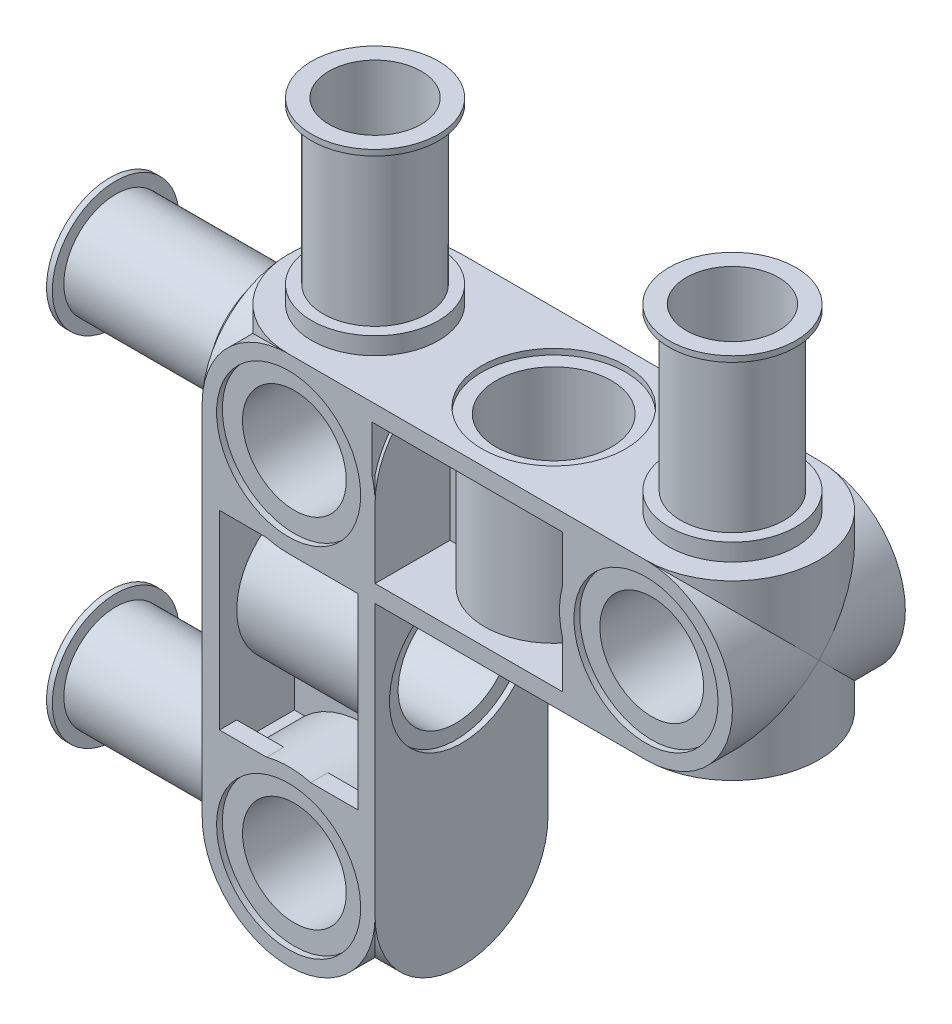
from build123d import *

# Parameters (mm, degrees)
EXTRUDE1_DEPTH       = 3.81
SKETCH2_R            = 2.794
CUT_EXTRUDE1_DEPTH   = 0.254
SKETCH3_R            = 2.794
EXTRUDE2_DEPTH       = 0.762
SKETCH5_R            = 2.286
SKETCH5_R_2          = 2.032
EXTRUDE4_DEPTH       = 7.112
SKETCH6_R            = 2.794
SKETCH6_R_2          = 2.032
EXTRUDE5_DEPTH       = 0.254
EXTRUDE6_DEPTH       = 7.62
SKETCH8_R            = 2.54
CUT_EXTRUDE2_DEPTH   = 3.556
SKETCH9_R            = 2.286
CUT_EXTRUDE3_DEPTH   = 8.62
SKETCH10_R           = 3.175
CUT_EXTRUDE4_DEPTH   = 0.254
CUT_EXTRUDE6_DEPTH   = 3.048
SKETCH13_R           = 2.54
CUT_EXTRUDE7_DEPTH   = 9.128
SKETCH14_R           = 3.175
CUT_EXTRUDE8_DEPTH   = 0.254
EXTRUDE8_DEPTH       = 7.112
EXTRUDE10_DEPTH      = 1
EXTRUDE10_DEPTH_BACK = 8.62
CIRPATTERN1_COUNT    = 2
CIRPATTERN1_ANGLE    = 90


with BuildPart() as part:
    # Sketch1 → Extrude1 (new body)
    with BuildSketch(Plane(origin=(0, 0, 0), x_dir=(1, 0, 0), z_dir=(0, 1, 0))):
        with BuildLine():
            Line((-7.874, 3.81), (7.874, 3.81))
            ThreePointArc((7.874, 3.81), (11.684, 0), (7.874, -3.81))
            Line((7.874, -3.81), (-7.874, -3.81))
            ThreePointArc((-7.874, -3.81), (-11.684, 0), (-7.874, 3.81))
        make_face()
    extrude(amount=EXTRUDE1_DEPTH)

    # Sketch2 → Cut-Extrude1 (cut)
    with BuildSketch(Plane.XZ):
        Circle(SKETCH2_R)
    extrude(amount=-CUT_EXTRUDE1_DEPTH, mode=Mode.SUBTRACT)

    # Sketch3 → Extrude2 (add)
    with BuildSketch(Plane.XZ):
        with Locations((7.874, 0)):
            Circle(SKETCH3_R)
        with Locations((-7.874, 0)):
            Circle(SKETCH3_R)
    extrude(amount=EXTRUDE2_DEPTH)

    # Sketch5 → Extrude4 (add)
    with BuildSketch(Plane.XZ.offset(0.762)):
        with Locations((7.874, 0)):
            Circle(SKETCH5_R)
        with Locations((7.874, 0)):
            Circle(SKETCH5_R_2, mode=Mode.SUBTRACT)
        with Locations((-7.874, 0)):
            Circle(SKETCH5_R)
        with Locations((-7.874, 0)):
            Circle(SKETCH5_R_2, mode=Mode.SUBTRACT)
    extrude(amount=EXTRUDE4_DEPTH)

    # Sketch6 → Extrude5 (add)
    with BuildSketch(Plane.XZ.offset(7.874)):
        with Locations((-7.874, 0)):
            Circle(SKETCH6_R)
        with Locations((-7.874, 0)):
            Circle(SKETCH6_R_2, mode=Mode.SUBTRACT)
        with Locations((7.874, 0)):
            Circle(SKETCH6_R)
        with Locations((7.874, 0)):
            Circle(SKETCH6_R_2, mode=Mode.SUBTRACT)
    extrude(amount=-EXTRUDE5_DEPTH)

    # Sketch7 → Extrude6 (add)
    with BuildSketch(Plane(origin=(0, 0, -3.81), x_dir=(-1, 0, 0), z_dir=(0, 0, -1))):
        with BuildLine():
            Line((-7.874, 0), (7.874, 0))
            ThreePointArc((7.874, 0), (10.568076836, 1.115923164), (11.684, 3.81))
            Line((11.684, 3.81), (7.874, 3.81))
            Line((7.874, 3.81), (-7.874, 3.81))
            Line((-7.874, 3.81), (-11.684, 3.81))
            ThreePointArc((-11.684, 3.81), (-10.568076836, 1.115923164), (-7.874, 0))
        make_face()
    extrude(amount=-EXTRUDE6_DEPTH)

    # Sketch8 → Cut-Extrude2 (cut)
    with BuildSketch(Plane(origin=(0, 3.81, 0), x_dir=(1, 0, 0), z_dir=(0, 1, 0))):
        Circle(SKETCH8_R)
    extrude(amount=-CUT_EXTRUDE2_DEPTH, mode=Mode.SUBTRACT)

    # Sketch9 → Cut-Extrude3 (cut, through all)
    with BuildSketch(Plane.XY.offset(3.81)):
        with Locations((7.874, 3.81)):
            Circle(SKETCH9_R)
        with Locations((-7.874, 3.81)):
            Circle(SKETCH9_R)
    extrude(amount=-CUT_EXTRUDE3_DEPTH, mode=Mode.SUBTRACT)

    # Sketch10 → Cut-Extrude4 (cut)
    with BuildSketch(Plane.XY.offset(3.81)):
        with Locations((7.874, 3.81)):
            Circle(SKETCH10_R)
        with Locations((-7.874, 3.81)):
            Circle(SKETCH10_R)
    cut_extrude4 = extrude(amount=-CUT_EXTRUDE4_DEPTH, mode=Mode.SUBTRACT)

    # Mirror2: Cut-Extrude4 across plane
    add(cut_extrude4.mirror(Plane.XY), mode=Mode.SUBTRACT)

    # Sketch11 → Cut-Extrude6 (cut)
    with BuildSketch(Plane(origin=(0, 3.81, 0), x_dir=(1, 0, 0), z_dir=(0, 1, 0))):
        with BuildLine():
            Line((-5.08, -0.508), (-5.08, -3.048))
            Line((-5.08, -3.048), (-4.191, -3.048))
            Line((-4.191, -3.048), (-4.191, -3.81))
            Line((-4.191, -3.81), (4.191, -3.81))
            Line((4.191, -3.81), (4.191, -3.048))
            Line((4.191, -3.048), (5.08, -3.048))
            Line((5.08, -3.048), (5.08, -0.508))
            Line((5.08, -0.508), (3.00536853, -0.508))
            ThreePointArc((3.00536853, -0.508), (0, -3.048), (-3.00536853, -0.508))
            Line((-3.00536853, -0.508), (-5.08, -0.508))
        make_face()
        with BuildLine():
            Line((5.08, 0.508), (5.08, 3.048))
            Line((5.08, 3.048), (4.191, 3.048))
            Line((4.191, 3.048), (4.191, 3.81))
            Line((4.191, 3.81), (-4.191, 3.81))
            Line((-4.191, 3.81), (-4.191, 3.048))
            Line((-4.191, 3.048), (-5.08, 3.048))
            Line((-5.08, 3.048), (-5.08, 0.508))
            Line((-5.08, 0.508), (-3.00536853, 0.508))
            ThreePointArc((-3.00536853, 0.508), (0, 3.048), (3.00536853, 0.508))
            Line((3.00536853, 0.508), (5.08, 0.508))
        make_face()
    extrude(amount=-CUT_EXTRUDE6_DEPTH, mode=Mode.SUBTRACT)

    # Sketch13 → Cut-Extrude7 (cut, through all)
    with BuildSketch(Plane(origin=(0, 0.254, 0), x_dir=(1, 0, 0), z_dir=(0, 1, 0))):
        Circle(SKETCH13_R)
    extrude(amount=-CUT_EXTRUDE7_DEPTH, mode=Mode.SUBTRACT)

    # Sketch14 → Cut-Extrude8 (cut)
    with BuildSketch(Plane.XZ):
        Circle(SKETCH14_R)
    extrude(amount=-CUT_EXTRUDE8_DEPTH, mode=Mode.SUBTRACT)

    # Sketch17 → Extrude8 (add)
    with BuildSketch(Plane.XY.offset(3.81)):
        with BuildLine():
            Line((-4.064, 3.81), (-4.699, 3.81))
            ThreePointArc((-4.699, 3.81), (-7.874, 0.635), (-11.049, 3.81))
            Line((-11.049, 3.81), (-11.684, 3.81))
            ThreePointArc((-11.684, 3.81), (-7.874, 0), (-4.064, 3.81))
        make_face()
    extrude8 = extrude(amount=-EXTRUDE8_DEPTH)

    # Mirror3: Extrude8 across plane
    add(extrude8.mirror(Plane(origin=(0, 0, 0), x_dir=(0, 0, 1), z_dir=(1, 0, 0))))

    # Mirror1: part across face


with BuildPart() as part_1:
    add(part.part)
    add(part.part.mirror(Plane(origin=(0, 3.81, 0.015641894), x_dir=(0, 0, 1), z_dir=(0, 1, 0))))

    # Sketch18 → Extrude10 (cut, two sides)
    with BuildSketch(Plane.XY.offset(3.81)) as extrude10_sk:
        Polygon((-86.944177943, 0), (-14.134519373, 0), (15.632648155, 0), (88.442306725, 0), (88.442306725, -145.61931714), (-86.944177943, -145.61931714), align=None)
    extrude(amount=EXTRUDE10_DEPTH, mode=Mode.SUBTRACT)
    extrude(extrude10_sk.sketch, amount=-EXTRUDE10_DEPTH_BACK, mode=Mode.SUBTRACT)


with BuildPart() as cirpattern1_1:
    # CirPattern1: pattern copy
    add(part_1.part.rotate(Axis((-7.874, 3.81, 0), (0, 0, -1)), 1 * CIRPATTERN1_ANGLE / (CIRPATTERN1_COUNT - 1)))


with BuildPart() as body_3:
    # Mirror4: mirrored copy
    add(cirpattern1_1.part.mirror(Plane(origin=(-7.874, 0, 0), x_dir=(0, 0, 1), z_dir=(1, 0, 0))))


with BuildPart() as part_2:
    add(part_1.part)

    # Combine1: union body 3
    add(body_3.part)


solid = part_2.part
